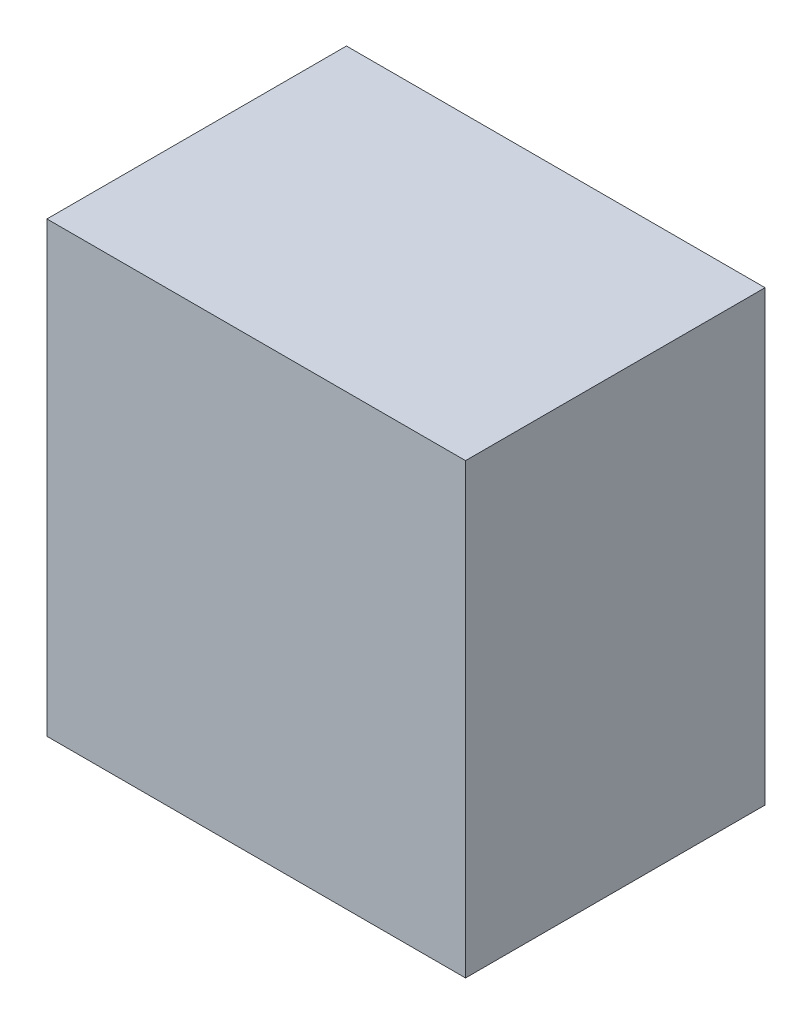
from build123d import *

# Parameters (mm, degrees)
SKETCH1_W           = 70.0024
SKETCH1_H           = 50.0888
BOSS_EXTRUDE1_DEPTH = 74.93


with BuildPart() as part:
    # Sketch1 → Boss-Extrude1 (new body)
    with BuildSketch(Plane(origin=(0, 0, 0), x_dir=(1, 0, 0), z_dir=(0, 1, 0))):
        Rectangle(SKETCH1_W, SKETCH1_H)
    extrude(amount=BOSS_EXTRUDE1_DEPTH)


solid = part.part
